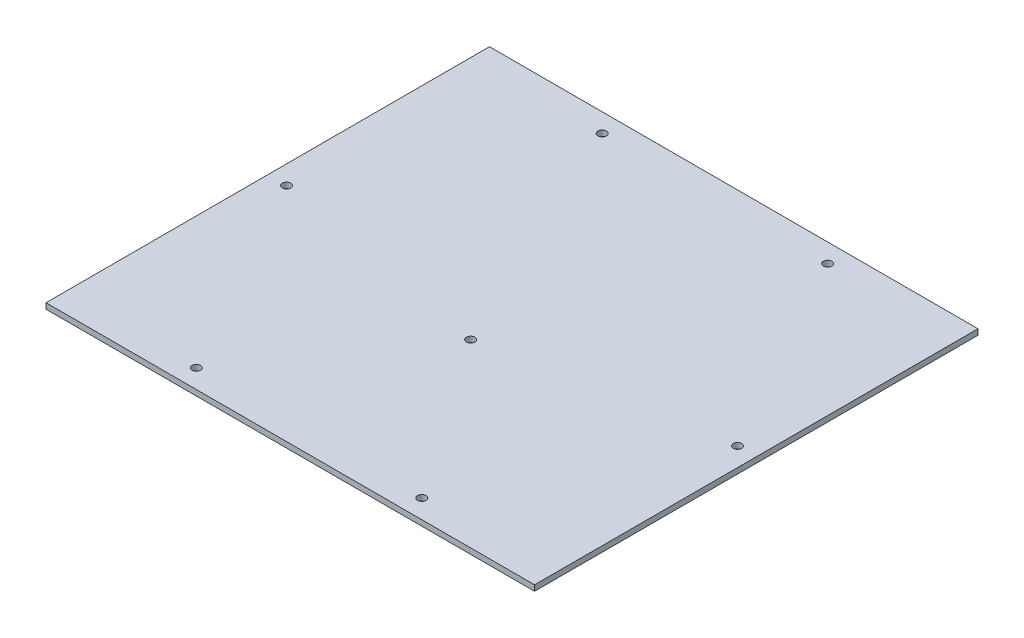
from build123d import *

# Parameters (mm, degrees)
SKETCH_1_W         = 260
SKETCH_1_H         = 236
SKETCH_1_R         = 2.25
EXTRUDE_1_DEPTH    = 3
SKETCH1_R          = 2.25
CUT_EXTRUDE1_DEPTH = 4


with BuildPart() as part:
    # Эскиз1 → Бобышка-Вытянуть1 (new body)
    with BuildSketch(Plane(origin=(0, 0, 0), x_dir=(1, 0, 0), z_dir=(0, 1, 0))):
        with Locations((130, 118)):
            Rectangle(SKETCH_1_W, SKETCH_1_H)
        with Locations((70, 226)):
            Circle(SKETCH_1_R, mode=Mode.SUBTRACT)
        with Locations((190, 226)):
            Circle(SKETCH_1_R, mode=Mode.SUBTRACT)
        with Locations((10, 118)):
            Circle(SKETCH_1_R, mode=Mode.SUBTRACT)
        with Locations((250, 118)):
            Circle(SKETCH_1_R, mode=Mode.SUBTRACT)
        with Locations((70, 10)):
            Circle(SKETCH_1_R, mode=Mode.SUBTRACT)
        with Locations((190, 10)):
            Circle(SKETCH_1_R, mode=Mode.SUBTRACT)
    extrude(amount=EXTRUDE_1_DEPTH)

    # Sketch1 → Cut-Extrude1 (cut, through all)
    with BuildSketch(Plane.XZ):
        with Locations((130, -96)):
            Circle(SKETCH1_R)
    extrude(amount=-CUT_EXTRUDE1_DEPTH, mode=Mode.SUBTRACT)


solid = part.part
